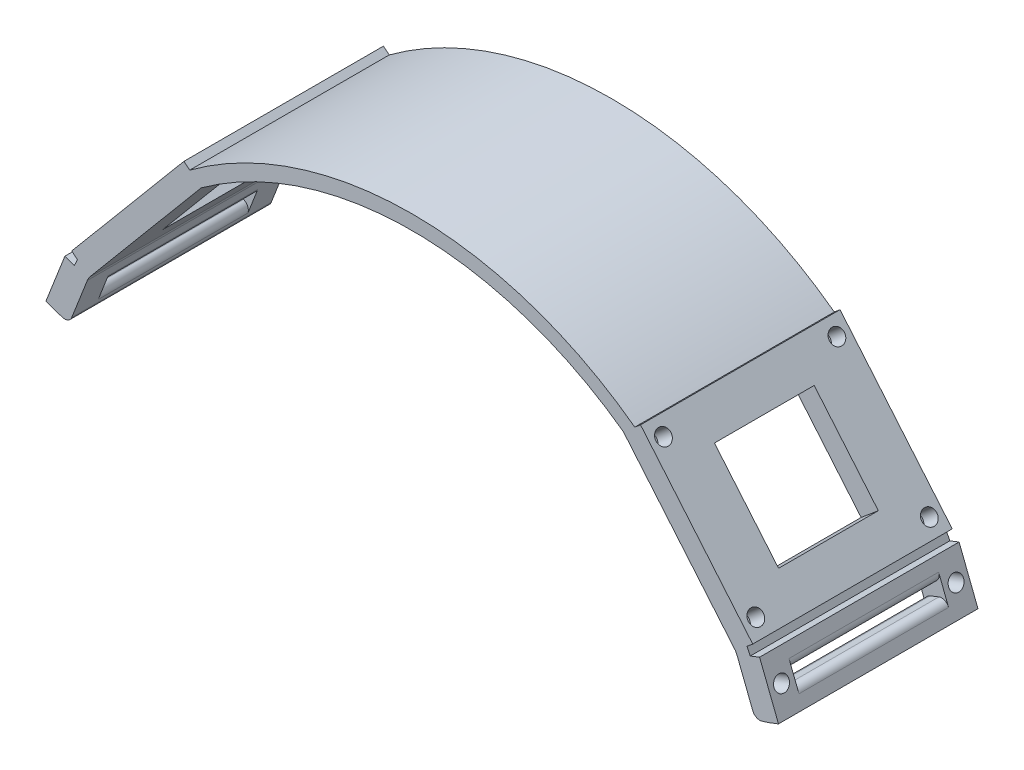
from build123d import *

# Parameters (mm, degrees)
BOSS_EXTRUDE1_DEPTH = 40
SKETCH8_W           = 40
SKETCH8_H           = 35
BOSS_EXTRUDE2_DEPTH = 1.5
SKETCH9_W           = 40
SKETCH9_H           = 35
BOSS_EXTRUDE3_DEPTH = 1.5
SKETCH11_R          = 1.5
CUT_EXTRUDE1_DEPTH  = 3.75
SKETCH12_R          = 1.5
CUT_EXTRUDE2_DEPTH  = 3.75
SKETCH4_W           = 20
SKETCH4_H           = 20
CUT_EXTRUDE3_DEPTH  = 4.5
CUT_EXTRUDE4_DEPTH  = 4.5
BOSS_EXTRUDE5_DEPTH = 40
SKETCH15_W          = 40
SKETCH15_H          = 10.404209308
SKETCH15_R          = 1.5
SKETCH15_W_2        = 30
SKETCH15_H_2        = 2.5
BOSS_EXTRUDE6_DEPTH = 2
SKETCH15_2_W        = 30
SKETCH15_2_H        = 2.5
CUT_EXTRUDE5_DEPTH  = 2.906774
SKETCH15_3_R        = 1.5
CUT_EXTRUDE6_DEPTH  = 2.156774
SKETCH17_W          = 40
SKETCH17_H          = 10.404209308
SKETCH17_R          = 1.5
SKETCH17_W_2        = 30
SKETCH17_H_2        = 2.5
BOSS_EXTRUDE7_DEPTH = 2
SKETCH17_2_R        = 1.5
CUT_EXTRUDE7_DEPTH  = 2.156774
SKETCH17_4_W        = 30
SKETCH17_4_H        = 2.5
CUT_EXTRUDE9_DEPTH  = 2.906774
FILLET1_R           = 1.5


with BuildPart() as part:
    # Sketch2 → Boss-Extrude1 (new body)
    with BuildSketch(Plane.XY):
        with BuildLine():
            Line((-67.116221114, 33.472568819), (-44.618654775, 60.284124329))
            ThreePointArc((-44.618654775, 60.284124329), (0, 75), (44.618654775, 60.284124329))
            Line((44.618654775, 60.284124329), (67.116221114, 33.472568819))
            ThreePointArc((67.116221114, 33.472568819), (67.449471383, 32.795865748), (67.77589897, 32.115845292))
            Line((67.77589897, 32.115845292), (65.142767665, 30.868126871))
            ThreePointArc((65.142767665, 30.868126871), (64.981306989, 31.206588688), (64.818087785, 31.54420599))
            Line((64.818087785, 31.54420599), (42.320521446, 58.3557615))
            ThreePointArc((42.320521446, 58.3557615), (0, 72.086208359), (-42.320521446, 58.3557615))
            Line((-42.320521446, 58.3557615), (-64.818087785, 31.54420599))
            ThreePointArc((-64.818087785, 31.54420599), (-64.981306989, 31.206588688), (-65.142767665, 30.868126871))
            Line((-65.142767665, 30.868126871), (-67.77589897, 32.115845292))
            ThreePointArc((-67.77589897, 32.115845292), (-67.449471383, 32.795865748), (-67.116221114, 33.472568819))
        make_face()
    extrude(amount=BOSS_EXTRUDE1_DEPTH)

    # Sketch8 → Boss-Extrude2 (add)
    with BuildSketch(Plane(origin=(-55.867437945, 46.878346574, 0), x_dir=(0, 0, 1), z_dir=(-0.766044443, 0.64278761, 0))):
        with Locations((20, 0)):
            Rectangle(SKETCH8_W, SKETCH8_H)
    extrude(amount=BOSS_EXTRUDE2_DEPTH)

    # Sketch9 → Boss-Extrude3 (add)
    with BuildSketch(Plane(origin=(55.867437945, 46.878346574, 0), x_dir=(0, 0, -1), z_dir=(0.766044443, 0.64278761, 0))):
        with Locations((-20, 0)):
            Rectangle(SKETCH9_W, SKETCH9_H)
    extrude(amount=BOSS_EXTRUDE3_DEPTH)

    # Sketch11 → Cut-Extrude1 (cut)
    with BuildSketch(Plane(origin=(-57.016504609, 47.842527989, 0), x_dir=(0, 0, 1), z_dir=(-0.766044443, 0.64278761, 0))):
        with Locations((37.39, 14.405)):
            Circle(SKETCH11_R)
        with Locations((2.61, 14.405)):
            Circle(SKETCH11_R)
        with Locations((2.61, -14.405)):
            Circle(SKETCH11_R)
        with Locations((37.39, -14.405)):
            Circle(SKETCH11_R)
    extrude(amount=-CUT_EXTRUDE1_DEPTH, mode=Mode.SUBTRACT)

    # Sketch12 → Cut-Extrude2 (cut)
    with BuildSketch(Plane(origin=(57.016504609, 47.842527989, 58.957611892), x_dir=(0.413175911, -0.492403877, -0.766044443), z_dir=(0.766044443, 0.64278761, 0))):
        with Locations((25.781104759, 2.828523492)):
            Circle(SKETCH12_R)
        with Locations((52.42413049, 25.184676556)):
            Circle(SKETCH12_R)
        with Locations((33.905419455, 47.254416963)):
            Circle(SKETCH12_R)
        with Locations((7.262393724, 24.898263898)):
            Circle(SKETCH12_R)
    extrude(amount=-CUT_EXTRUDE2_DEPTH, mode=Mode.SUBTRACT)

    # Sketch4 → Cut-Extrude3 (cut)
    with BuildSketch(Plane(origin=(-53.569304615, 44.949983745, 0), x_dir=(0, 0, -1), z_dir=(0.766044443, -0.64278761, 0))):
        with Locations((-20, 0)):
            Rectangle(SKETCH4_W, SKETCH4_H)
    extrude(amount=-CUT_EXTRUDE3_DEPTH, mode=Mode.SUBTRACT)

    # Sketch7 → Cut-Extrude4 (cut)
    with BuildSketch(Plane(origin=(53.569304615, 44.949983745, -58.957611892), x_dir=(0.413175911, -0.492403877, 0.766044443), z_dir=(-0.766044443, -0.64278761, 0))):
        Polygon((59.252471497, 36.664654087), (74.57336036, 49.52040628), (61.717608166, 64.841295143), (46.396719304, 51.985542949), align=None)
    extrude(amount=-CUT_EXTRUDE4_DEPTH, mode=Mode.SUBTRACT)

    # Sketch14 → Boss-Extrude5 (add)
    with BuildSketch(Plane.XY):
        Polygon((-68.787763199, 21.556091242), (-71.568228616, 22.427408515), (-67.77589897, 32.115845292), (-65.142767665, 30.868126871), align=None)
        Polygon((68.787763199, 21.556091242), (65.142767665, 30.868126871), (67.77589897, 32.115845292), (71.568228616, 22.427408515), align=None)
    extrude(amount=BOSS_EXTRUDE5_DEPTH)

    # Sketch15 → Boss-Extrude6 (add)
    with BuildSketch(Plane(origin=(-69.672063793, 27.271626904, 0), x_dir=(0, 0, -1), z_dir=(0.931203563, -0.364499553, 0))):
        with Locations((-20, 0)):
            Rectangle(SKETCH15_W, SKETCH15_H)
        with Locations((-37.5, 0)):
            Circle(SKETCH15_R, mode=Mode.SUBTRACT)
        with Locations((-2.5, 0)):
            Circle(SKETCH15_R, mode=Mode.SUBTRACT)
        with Locations((-20, 0)):
            Rectangle(SKETCH15_W_2, SKETCH15_H_2, mode=Mode.SUBTRACT)
    extrude(amount=-BOSS_EXTRUDE6_DEPTH)

    # Sketch15_2 → Cut-Extrude5 (cut)
    with BuildSketch(Plane(origin=(-69.672063793, 27.271626904, 0), x_dir=(0, 0, -1), z_dir=(0.931203563, -0.364499553, 0))):
        with Locations((-20, 0)):
            Rectangle(SKETCH15_2_W, SKETCH15_2_H)
    extrude(amount=CUT_EXTRUDE5_DEPTH, mode=Mode.SUBTRACT)

    # Sketch15_3 → Cut-Extrude6 (cut)
    with BuildSketch(Plane(origin=(-69.672063793, 27.271626904, 0), x_dir=(0, 0, -1), z_dir=(0.931203563, -0.364499553, 0))):
        with Locations((-37.5, 0)):
            Circle(SKETCH15_3_R)
        with Locations((-2.5, 0)):
            Circle(SKETCH15_3_R)
    extrude(amount=CUT_EXTRUDE6_DEPTH, mode=Mode.SUBTRACT)

    # Sketch17 → Boss-Extrude7 (add)
    with BuildSketch(Plane(origin=(69.672063793, 27.271626904, 0), x_dir=(0, 0, 1), z_dir=(-0.931203563, -0.364499553, 0))):
        with Locations((20, 0)):
            Rectangle(SKETCH17_W, SKETCH17_H)
        with Locations((2.5, 0)):
            Circle(SKETCH17_R, mode=Mode.SUBTRACT)
        with Locations((37.5, 0)):
            Circle(SKETCH17_R, mode=Mode.SUBTRACT)
        with Locations((20, 0)):
            Rectangle(SKETCH17_W_2, SKETCH17_H_2, mode=Mode.SUBTRACT)
    extrude(amount=-BOSS_EXTRUDE7_DEPTH)

    # Sketch17_2 → Cut-Extrude7 (cut)
    with BuildSketch(Plane(origin=(69.672063793, 27.271626904, 0), x_dir=(0, 0, 1), z_dir=(-0.931203563, -0.364499553, 0))):
        with Locations((37.5, 0)):
            Circle(SKETCH17_2_R)
        with Locations((2.5, 0)):
            Circle(SKETCH17_2_R)
    extrude(amount=CUT_EXTRUDE7_DEPTH, mode=Mode.SUBTRACT)

    # Sketch17_4 → Cut-Extrude9 (cut)
    with BuildSketch(Plane(origin=(69.672063793, 27.271626904, 0), x_dir=(0, 0, 1), z_dir=(-0.931203563, -0.364499553, 0))):
        with Locations((20, 0)):
            Rectangle(SKETCH17_4_W, SKETCH17_4_H)
    extrude(amount=CUT_EXTRUDE9_DEPTH, mode=Mode.SUBTRACT)

    # Fillet1
    fillet1_edges = [part.edges().sort_by_distance(p)[0] for p in [
        (-68.787763199, 21.556091242, 20),
        (68.787763199, 21.556091242, 20),
        (-71.990095361, 26.836621557, 20),
        (-71.078846477, 29.164630464, 20),
        (-67.42088993, 25.048104625, 20),
        (-66.509641046, 27.376113532, 20),
        (71.078846477, 29.164630464, 20),
        (71.990095361, 26.836621557, 20),
        (66.509641046, 27.376113532, 20),
        (67.42088993, 25.048104625, 20),
    ]]
    fillet(fillet1_edges, radius=FILLET1_R)


solid = part.part
